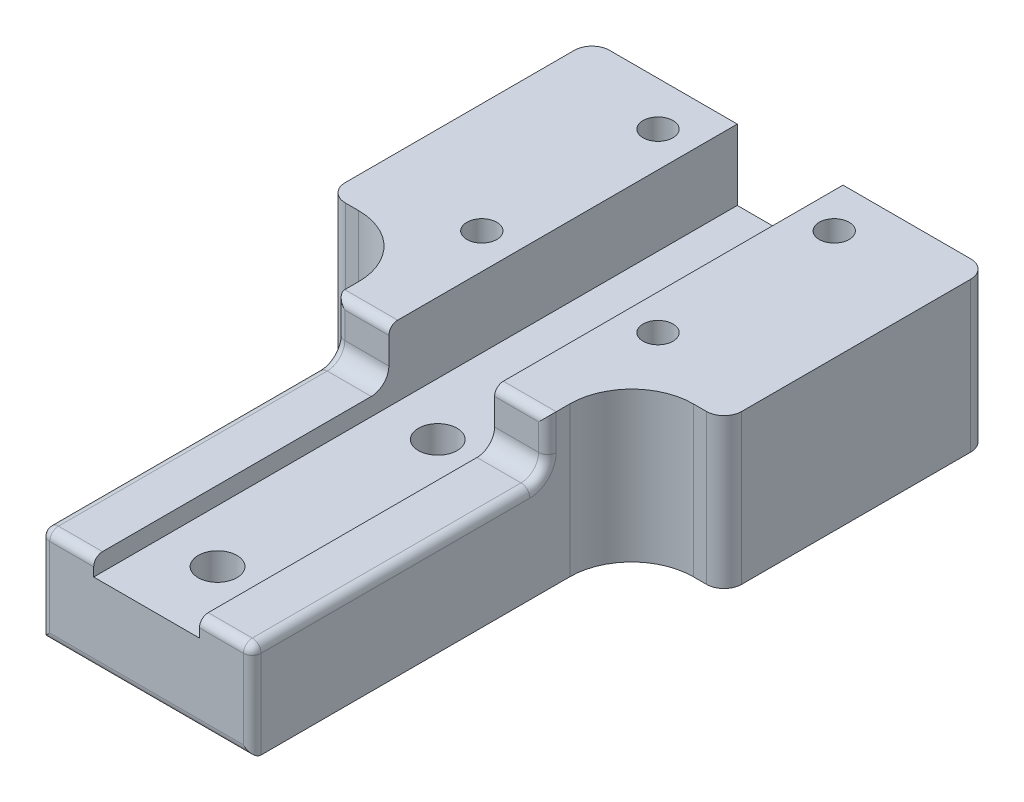
from build123d import *

# Parameters (mm, degrees)
SKETCH1_W           = 45
SKETCH1_H           = 30
SKETCH1_R           = 1.7
SKETCH1_W_2         = 24
SKETCH1_H_2         = 43.058371989
SKETCH1_R_2         = 2.2
BOSS_EXTRUDE2_DEPTH = 17
SKETCH5_W           = 12
SKETCH5_H           = 100
CUT_EXTRUDE1_DEPTH  = 8
SKETCH7_W           = 29.697028674
SKETCH7_H           = 34.988499238
CUT_EXTRUDE2_DEPTH  = 7
FILLET1_R           = 7
FILLET6_R           = 2
FILLET7_R           = 1


with BuildPart() as part:
    # Sketch1 → Boss-Extrude2 (new body)
    with BuildSketch(Plane(origin=(0, 0, 0), x_dir=(1, 0, 0), z_dir=(0, 1, 0))):
        Rectangle(SKETCH1_W, SKETCH1_H)
        with Locations((-10, 10)):
            Circle(SKETCH1_R, mode=Mode.SUBTRACT)
        with Locations((10, 10)):
            Circle(SKETCH1_R, mode=Mode.SUBTRACT)
        with Locations((10, -10)):
            Circle(SKETCH1_R, mode=Mode.SUBTRACT)
        with Locations((-10, -10)):
            Circle(SKETCH1_R, mode=Mode.SUBTRACT)
        with Locations((0, -36.529185995)):
            Rectangle(SKETCH1_W_2, SKETCH1_H_2)
        with Locations((0, -25)):
            Circle(SKETCH1_R_2, mode=Mode.SUBTRACT)
        with Locations((0, -50)):
            Circle(SKETCH1_R_2, mode=Mode.SUBTRACT)
    extrude(amount=-BOSS_EXTRUDE2_DEPTH)

    # Sketch5 → Cut-Extrude1 (cut)
    with BuildSketch(Plane(origin=(0, 0, 0), x_dir=(1, 0, 0), z_dir=(0, 1, 0))):
        with Locations((0, -16.465194583)):
            Rectangle(SKETCH5_W, SKETCH5_H)
    extrude(amount=-CUT_EXTRUDE1_DEPTH, mode=Mode.SUBTRACT)

    # Sketch7 → Cut-Extrude2 (cut, through all)
    with BuildSketch(Plane(origin=(0, -6, 0), x_dir=(1, 0, 0), z_dir=(0, 1, 0))):
        with Locations((-0.809918964, -42.047133079)):
            Rectangle(SKETCH7_W, SKETCH7_H)
    extrude(amount=CUT_EXTRUDE2_DEPTH, mode=Mode.SUBTRACT)

    # Fillet1
    fillet1_edges = [part.edges().sort_by_distance(p)[0] for p in [
        (-12, -8.5, 15),
        (12, -8.5, 15),
    ]]
    fillet(fillet1_edges, radius=FILLET1_R)

    # Fillet6
    fillet6_edges = [part.edges().sort_by_distance(p)[0] for p in [
        (22.5, -8.5, 15),
        (-22.5, -8.5, 15),
        (-22.5, -8.5, -15),
        (22.5, -8.5, -15),
        (9, -6, 24.55288346),
        (-9, -6, 24.55288346),
    ]]
    fillet(fillet6_edges, radius=FILLET6_R)

    # Fillet7
    fillet7_edges = [part.edges().sort_by_distance(p)[0] for p in [
        (-12, -2, 24.55288346),
        (12, -2, 24.55288346),
        (-12, -5.414213562, 25.138669897),
        (12, -5.414213562, 25.138669897),
        (-12, -11.5, 58.058371989),
        (12, -11.5, 58.058371989),
        (0, -17, 58.058371989),
        (9, 0, 24.55288346),
        (9, -6, 58.058371989),
        (12, -6, 42.305627724),
        (-9, 0, 24.55288346),
        (-9, -6, 58.058371989),
        (-12, -6, 42.305627724),
    ]]
    fillet(fillet7_edges, radius=FILLET7_R)


solid = part.part
